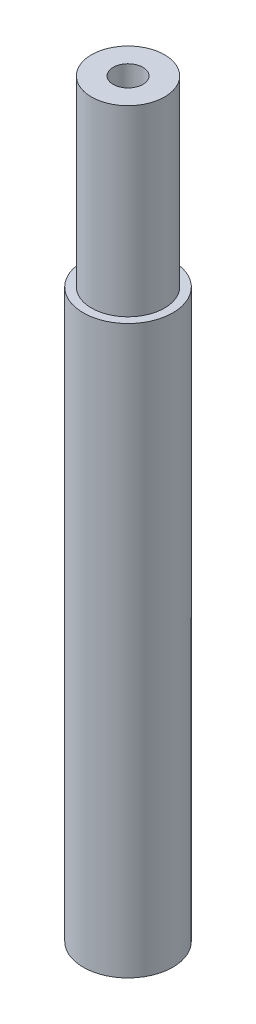
from build123d import *

# Parameters (mm, degrees)
SKETCH1_R           = 4
SKETCH1_R_2         = 1.625
BOSS_EXTRUDE2_DEPTH = 20
SKETCH2_R           = 4.9
BOSS_EXTRUDE3_DEPTH = 62
SKETCH6_R           = 1.625
CUT_EXTRUDE3_DEPTH  = 20


with BuildPart() as part:
    # Sketch1 → Boss-Extrude2 (new body)
    with BuildSketch(Plane(origin=(0, 0, 0), x_dir=(1, 0, 0), z_dir=(0, 1, 0))):
        Circle(SKETCH1_R)
        Circle(SKETCH1_R_2, mode=Mode.SUBTRACT)
    extrude(amount=BOSS_EXTRUDE2_DEPTH)

    # Sketch2 → Boss-Extrude3 (add)
    with BuildSketch(Plane.XZ):
        Circle(SKETCH2_R)
    extrude(amount=BOSS_EXTRUDE3_DEPTH)

    # Sketch6 → Cut-Extrude3 (cut)
    with BuildSketch(Plane.XZ.offset(62)):
        Circle(SKETCH6_R)
    extrude(amount=-CUT_EXTRUDE3_DEPTH, mode=Mode.SUBTRACT)


solid = part.part
